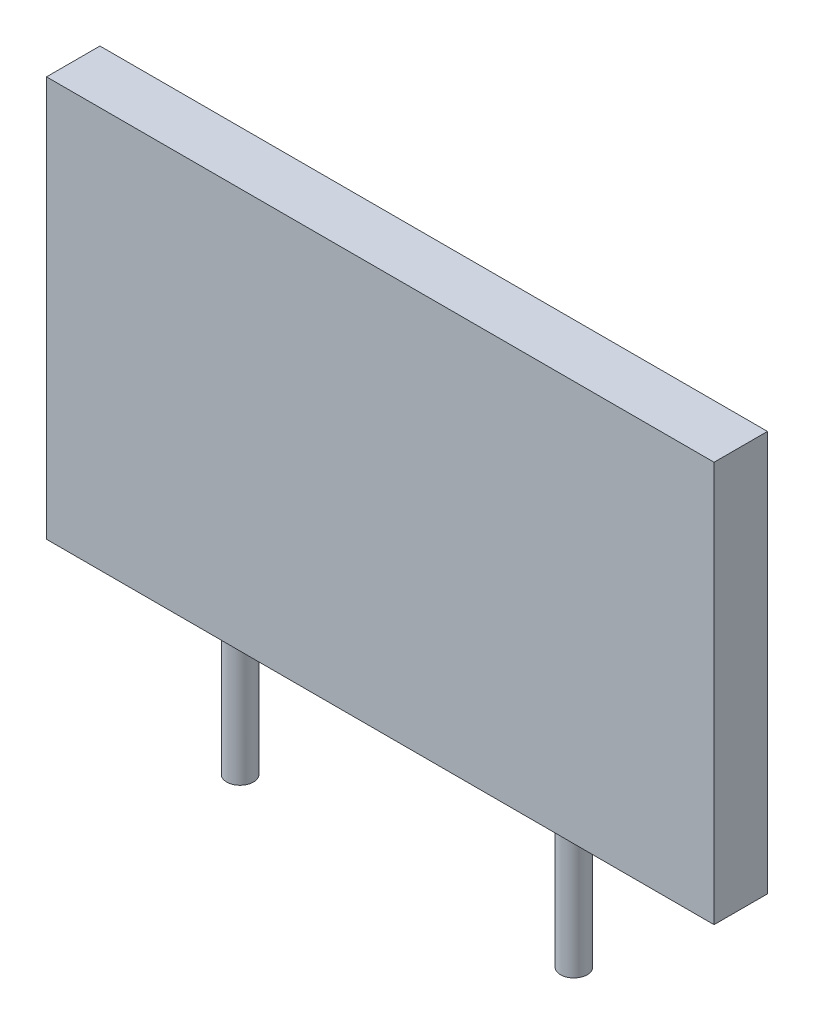
from build123d import *

# Parameters (mm, degrees)
SKETCH2_W           = 20
SKETCH2_H           = 150
BOSS_EXTRUDE2_DEPTH = 125
SKETCH3_R           = 5
BOSS_EXTRUDE3_DEPTH = 50


with BuildPart() as part:
    # Sketch2 → Boss-Extrude2 (new, symmetric)
    with BuildSketch(Plane(origin=(0, 0, 0), x_dir=(0, 0, -1), z_dir=(1, 0, 0))):
        with Locations((0, 75)):
            Rectangle(SKETCH2_W, SKETCH2_H)
    extrude(amount=BOSS_EXTRUDE2_DEPTH, both=True)

    # Sketch3 → Boss-Extrude3 (add)
    with BuildSketch(Plane.XZ):
        with Locations(Location((-62.5, 0, 0), (0, 0, 90))):
            Circle(SKETCH3_R)
    boss_extrude3 = extrude(amount=BOSS_EXTRUDE3_DEPTH)

    # Mirror1: Boss-Extrude3 across plane
    add(boss_extrude3.mirror(Plane(origin=(0, 0, 0), x_dir=(0, 0, 1), z_dir=(1, 0, 0))))


solid = part.part
